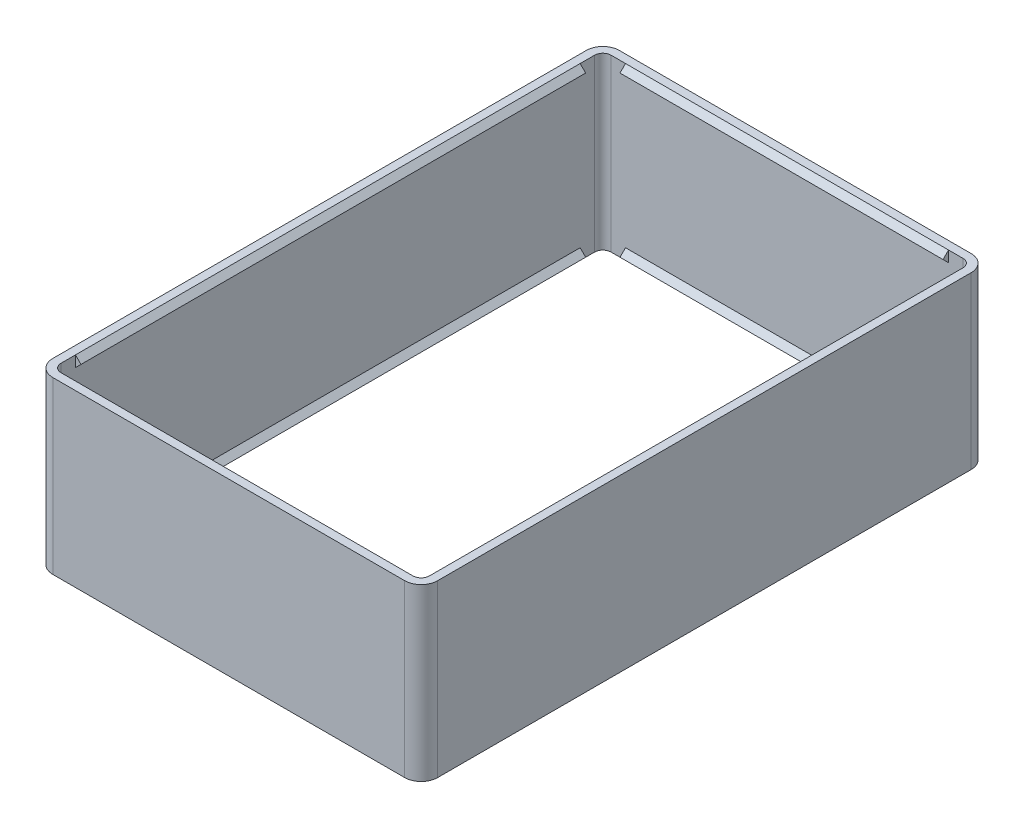
from build123d import *

# Parameters (mm, degrees)
SKETCH1_W           = 69.96
SKETCH1_H           = 102.98
SKETCH1_W_2         = 66.96
SKETCH1_H_2         = 99.98
BOSS_EXTRUDE1_DEPTH = 31.0002
FILLET1_R           = 3
FILLET2_R           = 1.5
BOSS_EXTRUDE2_START = -29.3587
BOSS_EXTRUDE2_DEPTH = 58.7174
BOSS_EXTRUDE3_START = -45.8687
BOSS_EXTRUDE3_DEPTH = 91.7374


with BuildPart() as part:
    # Sketch1 → Boss-Extrude1 (new body)
    with BuildSketch(Plane(origin=(0, 0, 0), x_dir=(1, 0, 0), z_dir=(0, 1, 0))):
        Rectangle(SKETCH1_W, SKETCH1_H)
        Rectangle(SKETCH1_W_2, SKETCH1_H_2, mode=Mode.SUBTRACT)
    extrude(amount=BOSS_EXTRUDE1_DEPTH)

    # Fillet1
    fillet1_edges = [part.edges().sort_by_distance(p)[0] for p in [
        (34.98, 15.5001, 51.49),
        (-34.98, 15.5001, 51.49),
        (-34.98, 15.5001, -51.49),
        (34.98, 15.5001, -51.49),
    ]]
    fillet(fillet1_edges, radius=FILLET1_R)

    # Fillet2
    fillet2_edges = [part.edges().sort_by_distance(p)[0] for p in [
        (-33.48, 15.5001, -49.99),
        (-33.48, 15.5001, 49.99),
        (33.48, 15.5001, 49.99),
        (33.48, 15.5001, -49.99),
    ]]
    fillet(fillet2_edges, radius=FILLET2_R)

    # Sketch2 → Boss-Extrude2 (add)
    with BuildSketch(Plane(origin=(0, 0, 0), x_dir=(0, 0, -1), z_dir=(1, 0, 0)).offset(BOSS_EXTRUDE2_START)):
        Polygon((-49.99, 31.0002), (-49.99, 29.0001972), (-48.9899986, 30.0001986), align=None)
        Polygon((49.99, 31.0002), (49.99, 29.0001972), (48.9899986, 30.0001986), align=None)
        Polygon((-49.99, 0), (-49.99, 2), (-48.99, 1), align=None)
        Polygon((49.99, 0), (49.99, 2), (48.99, 1), align=None)
    extrude(amount=BOSS_EXTRUDE2_DEPTH)

    # Sketch3 → Boss-Extrude3 (add)
    with BuildSketch(Plane.XY.offset(BOSS_EXTRUDE3_START)):
        Polygon((-33.48, 31.0002), (-33.48, 29.0001972), (-32.4799986, 30.0001986), align=None)
        Polygon((-33.48, 0), (-33.48, 2), (-32.48, 1), align=None)
        Polygon((33.48, 31.0002), (33.48, 29.0001972), (32.4799986, 30.0001986), align=None)
        Polygon((33.48, 0), (33.48, 2), (32.48, 1), align=None)
    extrude(amount=BOSS_EXTRUDE3_DEPTH)


solid = part.part
